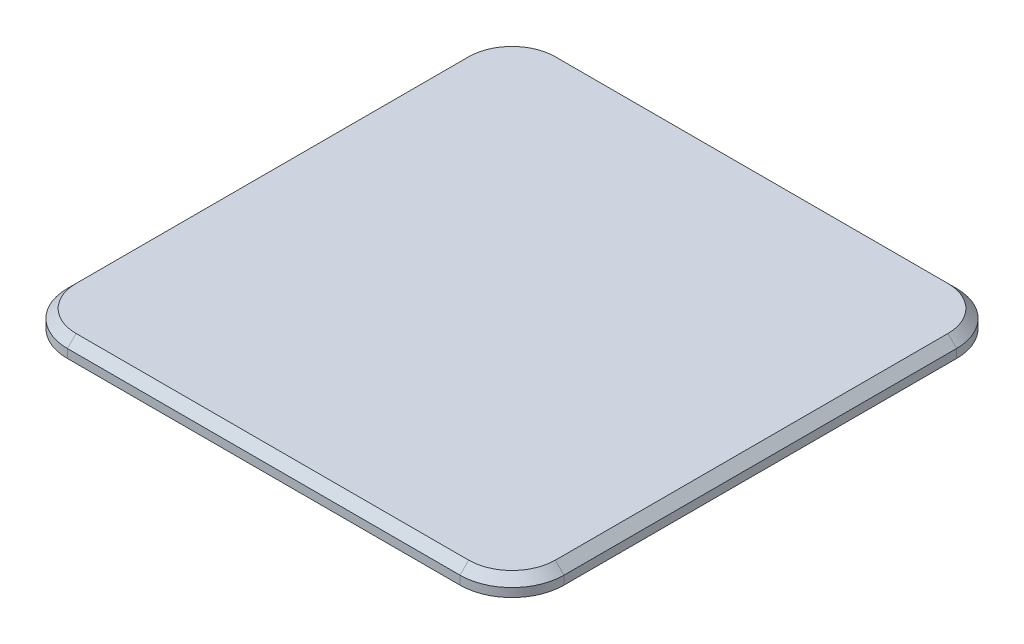
from build123d import *

# Parameters (mm, degrees)
BOSS_EXTRUDE1_DEPTH = 1
CHAMFER1_SIZE       = 0.5


with BuildPart() as part:
    # Sketch1 → Boss-Extrude1 (new body)
    with BuildSketch(Plane(origin=(0, 0, 0), x_dir=(1, 0, 0), z_dir=(0, 1, 0))):
        with BuildLine():
            Line((-11.325, 14.325), (11.325, 14.325))
            ThreePointArc((11.325, 14.325), (13.446320344, 13.446320344), (14.325, 11.325))
            Line((14.325, 11.325), (14.325, -11.325))
            ThreePointArc((14.325, -11.325), (13.446320344, -13.446320344), (11.325, -14.325))
            Line((11.325, -14.325), (-11.325, -14.325))
            ThreePointArc((-11.325, -14.325), (-13.446320344, -13.446320344), (-14.325, -11.325))
            Line((-14.325, -11.325), (-14.325, 11.325))
            ThreePointArc((-14.325, 11.325), (-13.446320344, 13.446320344), (-11.325, 14.325))
        make_face()
    extrude(amount=BOSS_EXTRUDE1_DEPTH)

    # Chamfer1
    chamfer1_edges = [part.edges().sort_by_distance(p)[0] for p in [
        (13.446320344, 1, 13.446320344),
        (14.325, 1, 0),
        (13.446320344, 1, -13.446320344),
        (0, 1, -14.325),
        (-13.446320344, 1, -13.446320344),
        (-14.325, 1, 0),
        (-13.446320344, 1, 13.446320344),
        (0, 1, 14.325),
    ]]
    chamfer(chamfer1_edges, length=CHAMFER1_SIZE)


solid = part.part
